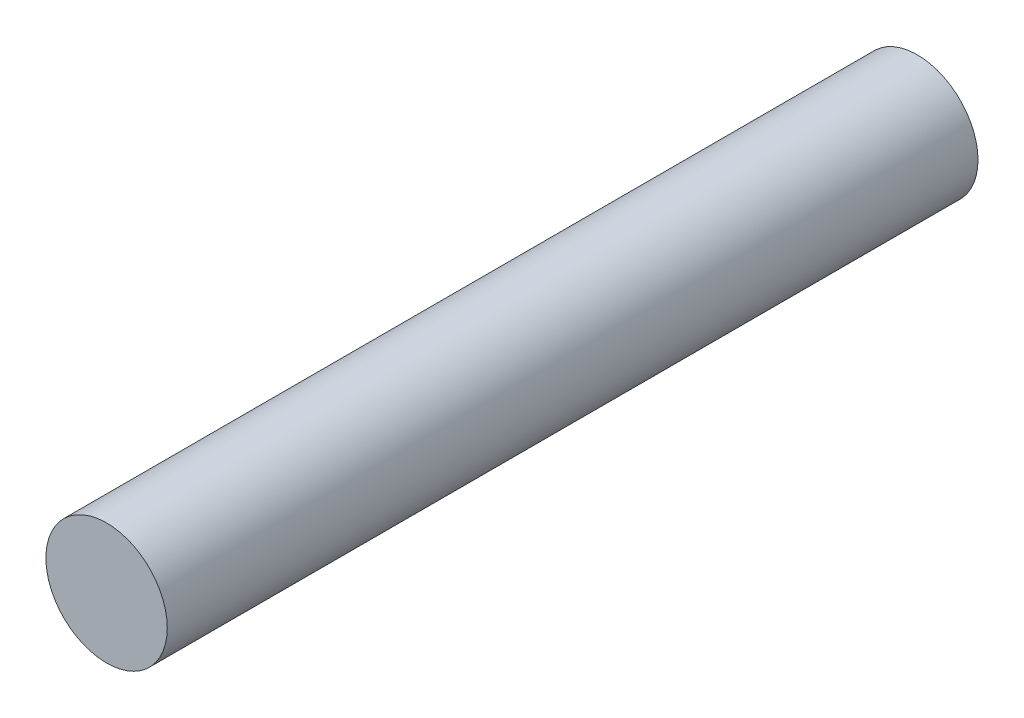
from build123d import *

# Parameters (mm, degrees)
IZIM1_R                     = 14.972138768
Y_KSEKLIK_EKSTR_ZYON1_DEPTH = 200


with BuildPart() as part:
    # Çizim1 → Yükseklik-Ekstrüzyon1 (new body)
    with BuildSketch(Plane.XY):
        with Locations((-22.55086379, 21.225392039)):
            Circle(IZIM1_R)
    extrude(amount=Y_KSEKLIK_EKSTR_ZYON1_DEPTH)


solid = part.part
